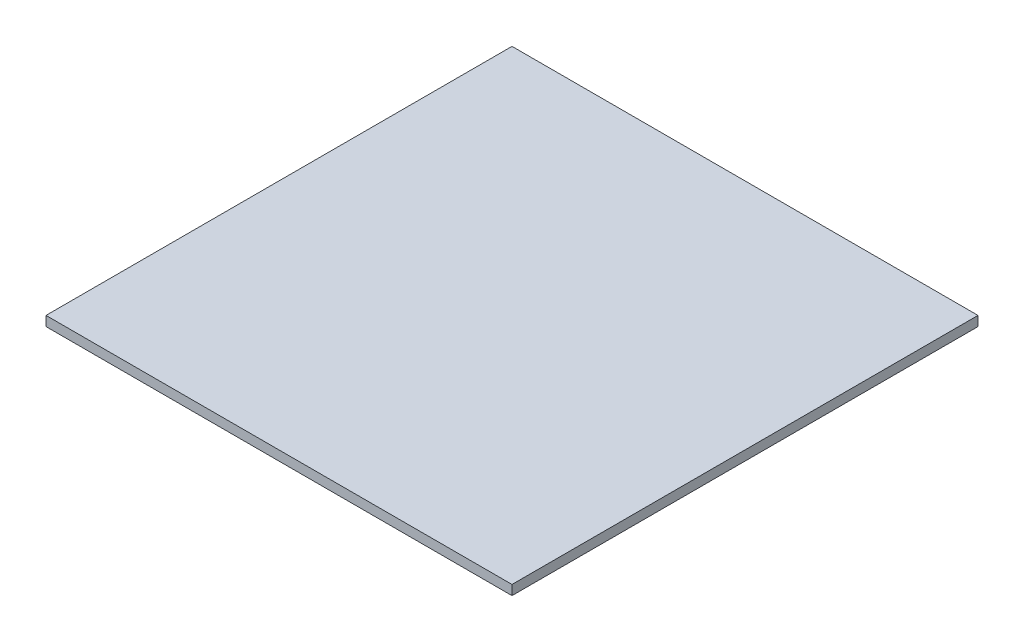
from build123d import *

# Parameters (mm, degrees)
SKETCH1_W           = 304.8
SKETCH1_H           = 304.8
BOSS_EXTRUDE1_DEPTH = 3.175


with BuildPart() as part:
    # Sketch1 → Boss-Extrude1 (new body, symmetric)
    with BuildSketch(Plane(origin=(0, 0, 0), x_dir=(1, 0, 0), z_dir=(0, 1, 0))):
        Rectangle(SKETCH1_W, SKETCH1_H)
    extrude(amount=BOSS_EXTRUDE1_DEPTH, both=True)


solid = part.part
